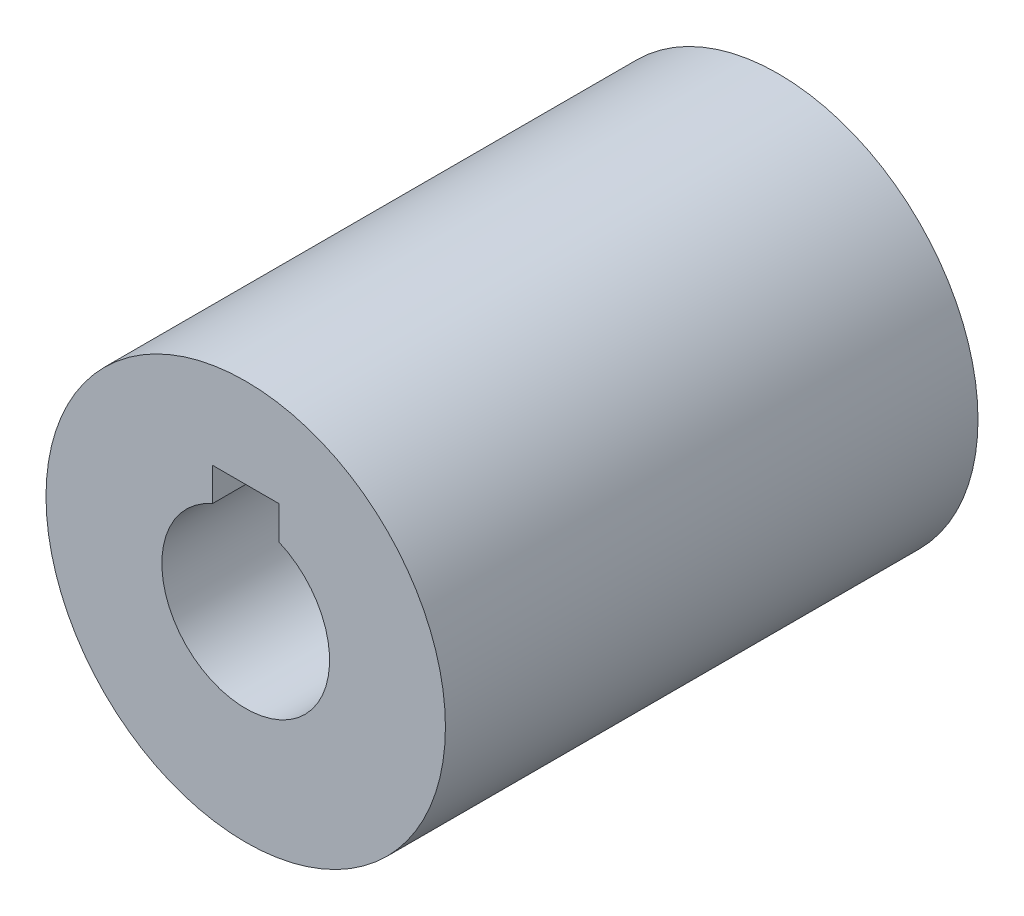
from build123d import *

# Parameters (mm, degrees)
SKETCH1_R           = 9.525
SKETCH1_R_2         = 4
BOSS_EXTRUDE1_DEPTH = 25.4
SKETCH2_W           = 3.175
SKETCH2_H           = 1.5875
CUT_EXTRUDE1_DEPTH  = 26.4


with BuildPart() as part:
    # Sketch1 → Boss-Extrude1 (new body)
    with BuildSketch(Plane.XY):
        Circle(SKETCH1_R)
        Circle(SKETCH1_R_2, mode=Mode.SUBTRACT)
    extrude(amount=BOSS_EXTRUDE1_DEPTH)

    # Sketch2 → Cut-Extrude1 (cut, through all)
    with BuildSketch(Plane.XY.offset(25.4)):
        with Locations((0, 4.465240671)):
            Rectangle(SKETCH2_W, SKETCH2_H)
    extrude(amount=-CUT_EXTRUDE1_DEPTH, mode=Mode.SUBTRACT)


solid = part.part
